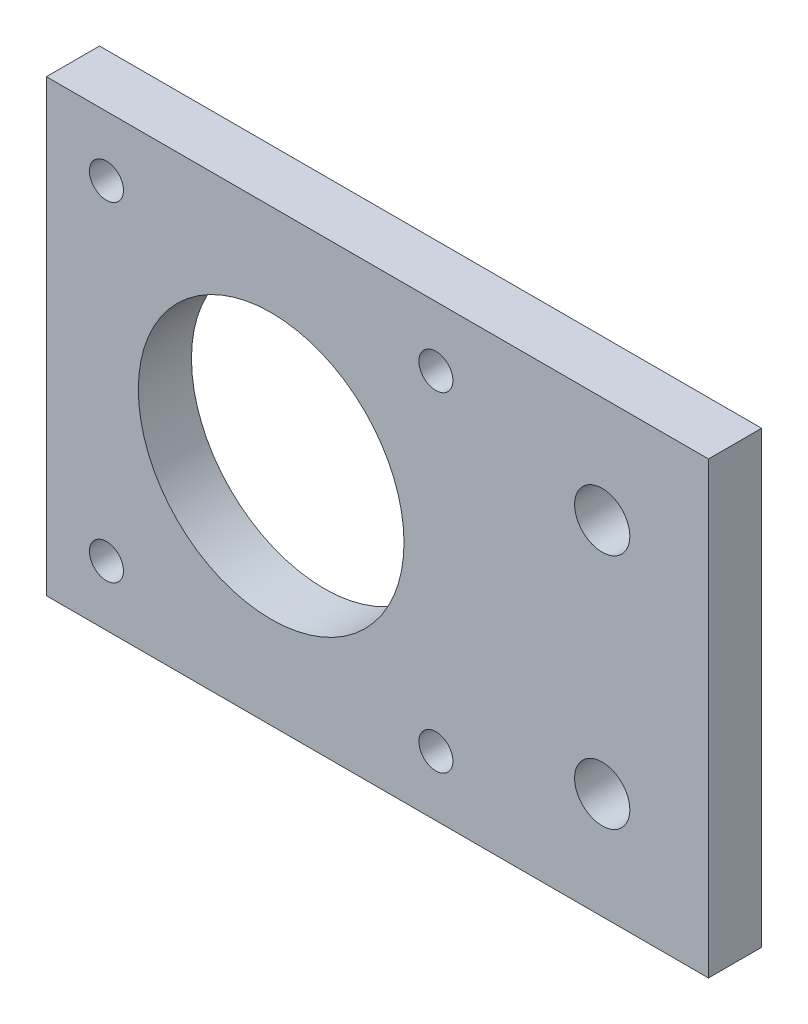
from build123d import *

# Parameters (mm, degrees)
SKETCH2_W           = 42.3
SKETCH2_H           = 42.3
SKETCH2_R           = 1.6
SKETCH2_W_2         = 20
SKETCH2_R_2         = 2.6
BOSS_EXTRUDE1_DEPTH = 5
SKETCH3_R           = 12.5
CUT_EXTRUDE1_DEPTH  = 10


with BuildPart() as part:
    # Sketch2 → Boss-Extrude1 (new body)
    with BuildSketch(Plane.XY):
        Rectangle(SKETCH2_W, SKETCH2_H)
        with Locations((-15.5, -15.5)):
            Circle(SKETCH2_R, mode=Mode.SUBTRACT)
        with Locations((15.5, 15.5)):
            Circle(SKETCH2_R, mode=Mode.SUBTRACT)
        with Locations((15.5, -15.5)):
            Circle(SKETCH2_R, mode=Mode.SUBTRACT)
        with Locations((-15.5, 15.5)):
            Circle(SKETCH2_R, mode=Mode.SUBTRACT)
        with Locations((31.15, 0)):
            Rectangle(SKETCH2_W_2, SKETCH2_H)
        with Locations((31.15, -11.15)):
            Circle(SKETCH2_R_2, mode=Mode.SUBTRACT)
        with Locations((31.15, 11.15)):
            Circle(SKETCH2_R_2, mode=Mode.SUBTRACT)
    extrude(amount=BOSS_EXTRUDE1_DEPTH)

    # Sketch3 → Cut-Extrude1 (cut)
    with BuildSketch(Plane(origin=(0, 0, 0), x_dir=(-1, 0, 0), z_dir=(0, 0, -1))):
        Circle(SKETCH3_R)
    extrude(amount=-CUT_EXTRUDE1_DEPTH, mode=Mode.SUBTRACT)


solid = part.part
